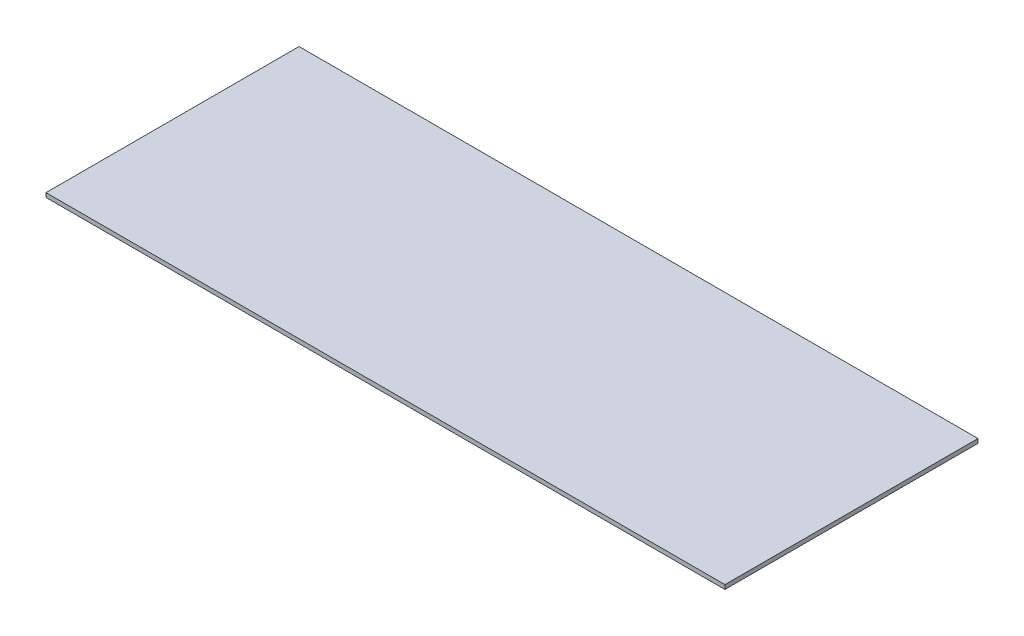
from build123d import *

# Parameters (mm, degrees)
SKETCH1_W           = 485.582593466
SKETCH1_H           = 181
BOSS_EXTRUDE1_DEPTH = 3


with BuildPart() as part:
    # Sketch1 → Boss-Extrude1 (new body)
    with BuildSketch(Plane(origin=(0, 0, 0), x_dir=(1, 0, 0), z_dir=(0, 1, 0))):
        with Locations((77.66771966, 90.5)):
            Rectangle(SKETCH1_W, SKETCH1_H)
    extrude(amount=BOSS_EXTRUDE1_DEPTH)


solid = part.part
